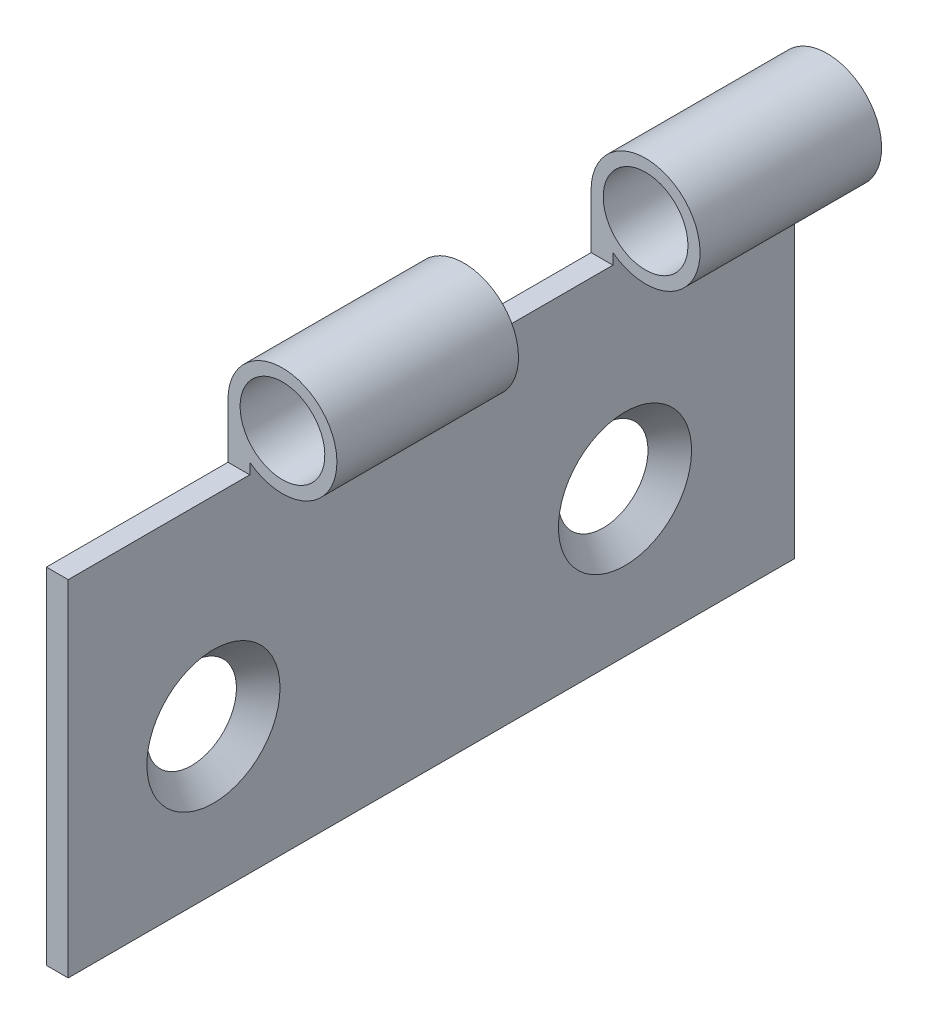
from build123d import *

# Parameters (mm, degrees)
SCHIZZO1_W                              = 0.9
SCHIZZO1_H                              = 16.5
ESTRUSIONE_SOTTILE1_DEPTH               = 15
SCHIZZO2_R                              = 2.25
SCHIZZO4_R                              = 1.75
TAGLIO_ESTRUSIONE1_DEPTH                = 36.662480284
SCHIZZO7_W                              = 7.5
SCHIZZO7_H                              = 4.5
TAGLIO_ESTRUSIONE13_DEPTH               = 10
FORO_SVASATO_PER_VITE_M2_5_1_AT_2_COUNT = 2
FORO_SVASATO_PER_VITE_M2_5_1_AT_2_PITCH = 17


with BuildPart() as part:
    # Schizzo1 → Estrusione-Sottile1 (new, symmetric)
    with BuildSketch(Plane.XY):
        with Locations((0.45, 8.25)):
            Rectangle(SCHIZZO1_W, SCHIZZO1_H)
    extrude(amount=ESTRUSIONE_SOTTILE1_DEPTH, both=True)

    # Sweep1: sweep along a curve in space
    with BuildLine() as sweep1_path:
        Line((0.9, 16.5, 15), (0.9, 16.5, -15))
    # Schizzo2 → Sweep1 (sweep)
    with BuildSketch(Plane.XY.offset(15)):
        with Locations((2.25, 16.5)):
            Circle(SCHIZZO2_R)
    sweep(path=sweep1_path.line)

    # Schizzo4 → Taglio-Estrusione1 (cut, through all)
    with BuildSketch(Plane.XY.offset(15)):
        with Locations((2.25, 16.5)):
            Circle(SCHIZZO4_R)
    extrude(amount=-TAGLIO_ESTRUSIONE1_DEPTH, mode=Mode.SUBTRACT)

    # Schizzo7 → Taglio-Estrusione13 (cut)
    with BuildSketch(Plane.ZY):
        with Locations((11.25, 16.5)):
            Rectangle(SCHIZZO7_W, SCHIZZO7_H)
        with Locations((-3.75, 16.5)):
            Rectangle(SCHIZZO7_W, SCHIZZO7_H)
    extrude(amount=-TAGLIO_ESTRUSIONE13_DEPTH, mode=Mode.SUBTRACT)

    # Schizzo8 → Foro svasato per Vite M2.5-1 (revolve, cut)
    with BuildSketch(Plane(origin=(0.9, 6, 9), x_dir=(0, 0, -1), z_dir=(0, 1, 0))):
        Polygon((0, 0), (0, 0.9), (1.45, 0.9), (1.45, 1.3), (2.75, 0), align=None)
    foro_svasato_per_vite_m2_5_1 = revolve(axis=Axis((7.25, 6, 9), (-1, 0, 0)), mode=Mode.SUBTRACT)

    # Foro svasato per Vite M2.5-1 at 2: Foro svasato per Vite M2.5-1 ×2
    with Locations(*[(0, 0, -i * FORO_SVASATO_PER_VITE_M2_5_1_AT_2_PITCH) for i in range(1, FORO_SVASATO_PER_VITE_M2_5_1_AT_2_COUNT)]):
        add(foro_svasato_per_vite_m2_5_1, mode=Mode.SUBTRACT)


solid = part.part
